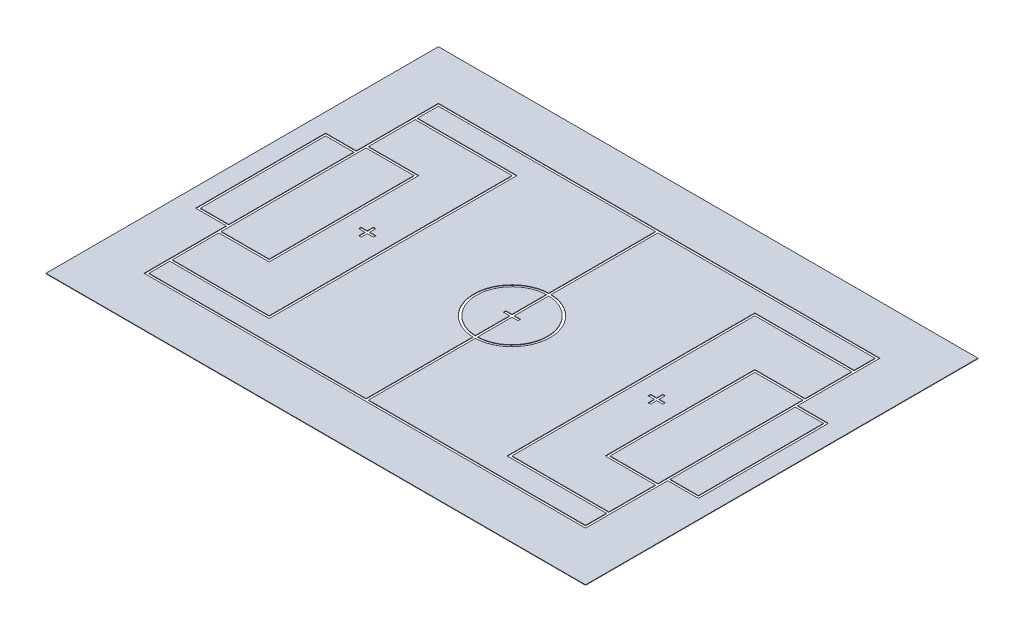
from build123d import *

# Parameters (mm, degrees)
BOSS_EXTRUDE1_DEPTH    = 10
BOSS_EXTRUDE1_2_DEPTH  = 10
BOSS_EXTRUDE1_3_DEPTH  = 10
BOSS_EXTRUDE1_4_DEPTH  = 10
BOSS_EXTRUDE1_5_DEPTH  = 10
SKETCH1_W              = 975
SKETCH1_H              = 2950
BOSS_EXTRUDE1_6_DEPTH  = 10
SKETCH1_W_2            = 575
SKETCH1_H_2            = 2550
BOSS_EXTRUDE1_7_DEPTH  = 10
BOSS_EXTRUDE1_8_DEPTH  = 10
BOSS_EXTRUDE1_9_DEPTH  = 10
BOSS_EXTRUDE1_10_DEPTH = 10
SKETCH1_W_3            = 11000
SKETCH1_H_3            = 8000
BOSS_EXTRUDE1_11_DEPTH = 10


with BuildPart() as part:
    # Sketch1 → Boss-Extrude1 (new body)
    with BuildSketch(Plane(origin=(0, 0, 0), x_dir=(1, 0, 0), z_dir=(0, 1, 0))):
        with BuildLine():
            Line((25, -25), (25, -723.591162127))
            ThreePointArc((25, -723.591162127), (724.022907033, 0), (25, 723.591162127))
            Line((25, 723.591162127), (25, 25))
            Line((25, 25), (150, 25))
            Line((150, 25), (150, -25))
            Line((150, -25), (25, -25))
        make_face()
    extrude(amount=BOSS_EXTRUDE1_DEPTH)


with BuildPart() as body_2:
    # Sketch1 → Boss-Extrude1 2 (new body)
    with BuildSketch(Plane(origin=(0, 0, 0), x_dir=(1, 0, 0), z_dir=(0, 1, 0))):
        with BuildLine():
            Line((-25, 723.591162127), (-25, 25))
            Line((-25, 25), (-150, 25))
            Line((-150, 25), (-150, -25))
            Line((-150, -25), (-25, -25))
            Line((-25, -25), (-25, -723.591162127))
            ThreePointArc((-25, -723.591162127), (-724.022907033, 0), (-25, 723.591162127))
        make_face()
    extrude(amount=BOSS_EXTRUDE1_2_DEPTH)


with BuildPart() as body_3:
    # Sketch1 → Boss-Extrude1 3 (new body)
    with BuildSketch(Plane(origin=(0, 0, 0), x_dir=(1, 0, 0), z_dir=(0, 1, 0))):
        with BuildLine():
            ThreePointArc((-25, 773.682215065), (-774.086022292, 0), (-25, -773.682215065))
            Line((-25, -773.682215065), (-25, -2950))
            Line((-25, -2950), (-4450, -2950))
            Line((-4450, -2950), (-4450, -2525))
            Line((-4450, -2525), (-2425, -2525))
            Line((-2425, -2525), (-2425, 2525))
            Line((-2425, 2525), (-4450, 2525))
            Line((-4450, 2525), (-4450, 2950))
            Line((-4450, 2950), (-25, 2950))
            Line((-25, 2950), (-25, 773.682215065))
        make_face()
    extrude(amount=BOSS_EXTRUDE1_3_DEPTH)


with BuildPart() as body_4:
    # Sketch1 → Boss-Extrude1 4 (new body)
    with BuildSketch(Plane(origin=(0, 0, 0), x_dir=(1, 0, 0), z_dir=(0, 1, 0))):
        with BuildLine():
            ThreePointArc((25, -773.682215065), (774.086022292, 0), (25, 773.682215065))
            Line((25, 773.682215065), (25, 2950))
            Line((25, 2950), (4450, 2950))
            Line((4450, 2950), (4450, 2525))
            Line((4450, 2525), (2425, 2525))
            Line((2425, 2525), (2425, -2525))
            Line((2425, -2525), (4450, -2525))
            Line((4450, -2525), (4450, -2950))
            Line((4450, -2950), (25, -2950))
            Line((25, -2950), (25, -773.682215065))
        make_face()
    extrude(amount=BOSS_EXTRUDE1_4_DEPTH)


with BuildPart() as body_5:
    # Sketch1 → Boss-Extrude1 5 (new body)
    with BuildSketch(Plane(origin=(0, 0, 0), x_dir=(1, 0, 0), z_dir=(0, 1, 0))):
        Polygon((4450, -1525), (4450, -2475), (2475, -2475), (2475, 2475), (4450, 2475), (4450, 1525), (3425, 1525), (3425, -1525), align=None)
        Polygon((2975, 150), (2925, 150), (2925, 25), (2800, 25), (2800, -25), (2925, -25), (2925, -150), (2975, -150), (2975, -25), (3100, -25), (3100, 25), (2975, 25), align=None, mode=Mode.SUBTRACT)
    extrude(amount=BOSS_EXTRUDE1_5_DEPTH)


with BuildPart() as body_6:
    # Sketch1 → Boss-Extrude1 6 (new body)
    with BuildSketch(Plane(origin=(0, 0, 0), x_dir=(1, 0, 0), z_dir=(0, 1, 0))):
        with Locations((3962.5, 0)):
            Rectangle(SKETCH1_W, SKETCH1_H)
    extrude(amount=BOSS_EXTRUDE1_6_DEPTH)


with BuildPart() as body_7:
    # Sketch1 → Boss-Extrude1 7 (new body)
    with BuildSketch(Plane(origin=(0, 0, 0), x_dir=(1, 0, 0), z_dir=(0, 1, 0))):
        with Locations((4787.5, 0)):
            Rectangle(SKETCH1_W_2, SKETCH1_H_2)
    extrude(amount=BOSS_EXTRUDE1_7_DEPTH)


with BuildPart() as body_8:
    # Sketch1 → Boss-Extrude1 8 (new body)
    with BuildSketch(Plane(origin=(0, 0, 0), x_dir=(1, 0, 0), z_dir=(0, 1, 0))):
        Polygon((-3425, -1525), (-4450, -1525), (-4450, -2475), (-2475, -2475), (-2475, 2475), (-4450, 2475), (-4450, 1525), (-3425, 1525), align=None)
        Polygon((-2925, -25), (-2800, -25), (-2800, 25), (-2925, 25), (-2925, 150), (-2975, 150), (-2975, 25), (-3100, 25), (-3100, -25), (-2975, -25), (-2975, -150), (-2925, -150), align=None, mode=Mode.SUBTRACT)
    extrude(amount=BOSS_EXTRUDE1_8_DEPTH)


with BuildPart() as body_9:
    # Sketch1 → Boss-Extrude1 9 (new body)
    with BuildSketch(Plane(origin=(0, 0, 0), x_dir=(1, 0, 0), z_dir=(0, 1, 0))):
        with Locations((-3962.5, 0)):
            Rectangle(SKETCH1_W, SKETCH1_H)
    extrude(amount=BOSS_EXTRUDE1_9_DEPTH)


with BuildPart() as body_10:
    # Sketch1 → Boss-Extrude1 10 (new body)
    with BuildSketch(Plane(origin=(0, 0, 0), x_dir=(1, 0, 0), z_dir=(0, 1, 0))):
        with Locations((-4787.5, 0)):
            Rectangle(SKETCH1_W_2, SKETCH1_H_2)
    extrude(amount=BOSS_EXTRUDE1_10_DEPTH)


with BuildPart() as body_11:
    # Sketch1 → Boss-Extrude1 11 (new body)
    with BuildSketch(Plane(origin=(0, 0, 0), x_dir=(1, 0, 0), z_dir=(0, 1, 0))):
        Rectangle(SKETCH1_W_3, SKETCH1_H_3)
        Polygon((5125, -1325), (4500, -1325), (4500, -3000), (-4500, -3000), (-4500, -1325), (-5125, -1325), (-5125, 1325), (-4500, 1325), (-4500, 3000), (4500, 3000), (4500, 1325), (5125, 1325), align=None, mode=Mode.SUBTRACT)
    extrude(amount=BOSS_EXTRUDE1_11_DEPTH)


solid = Compound([part.part, body_2.part, body_3.part, body_4.part, body_5.part, body_6.part, body_7.part, body_8.part, body_9.part, body_10.part, body_11.part])
